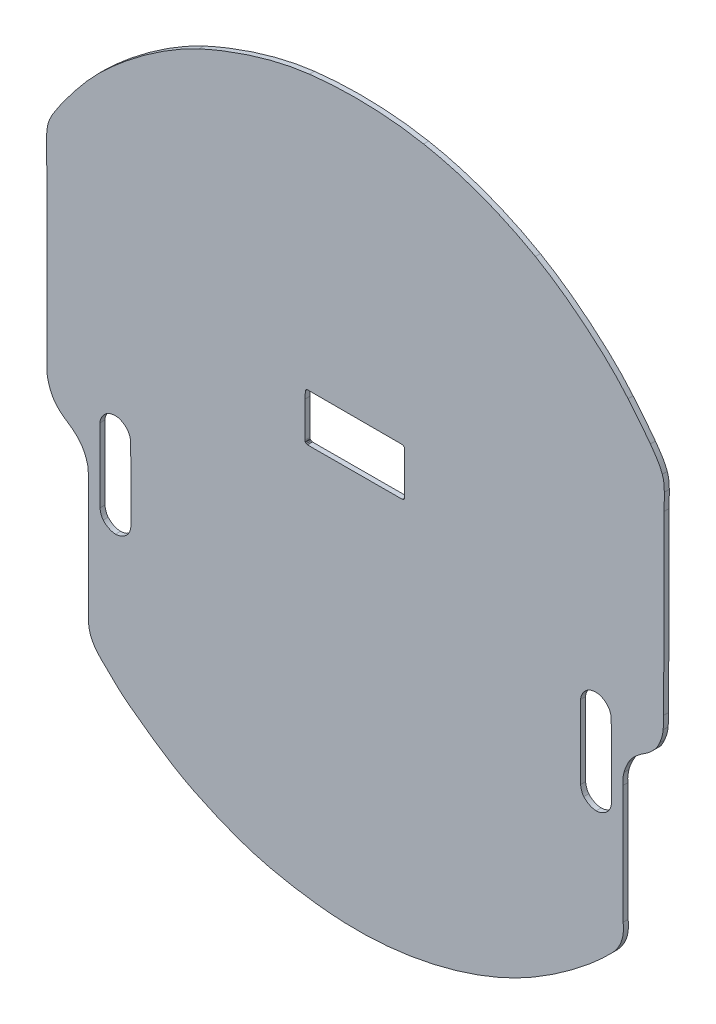
from build123d import *

# Parameters (mm, degrees)
BOSS_EXTRUDE1_DEPTH = 3.09


with BuildPart() as part:
    # Model → Boss-Extrude1 (new body)
    with BuildSketch(Plane.XY):
        with BuildLine():
            Line((32.991394077, 407.583971318), (33.227511856, 281.581752378))
            add(Edge.make_bspline(
                [(33.227511856, 281.581752378), (32.868682929, 277.527273844), (35.306656225, 271.332269837)],
                knots=[0, 0, 0, 1, 1, 1], degree=2))
            add(Edge.make_bspline(
                [(35.306656225, 271.332269837), (37.027868592, 266.958587981), (39.985006105, 263.165547305), (46.21976096, 259.169518249)],
                knots=[0, 0, 0, 0, 1, 1, 1, 1], degree=3))
            add(Edge.make_bspline(
                [(46.21976096, 259.169518249), (49.167061196, 257.280507614), (52.004779981, 254.877932524), (54.061744955, 252.177633115)],
                knots=[0, 0, 0, 0, 1, 1, 1, 1], degree=3))
            add(Edge.make_bspline(
                [(54.061744955, 252.177633115), (55.178759085, 250.71126606), (55.744043669, 249.636275438), (56.710796301, 247.517826276)],
                knots=[0, 0, 0, 0, 1, 1, 1, 1], degree=3))
            add(Edge.make_bspline(
                [(56.710796301, 247.517826276), (57.341702876, 246.135318374), (57.260729106, 246.533563849), (58.175067961, 243.47314552)],
                knots=[0, 0, 0, 0, 1, 1, 1, 1], degree=3))
            add(Edge.make_bspline(
                [(58.175067961, 243.47314552), (58.245897129, 243.236067231), (58.475340473, 242.643778545), (58.587518769, 241.756829152)],
                knots=[0, 0, 0, 0, 1, 1, 1, 1], degree=3))
            add(Edge.make_bspline(
                [(58.587518769, 241.756829152), (58.752115659, 240.455381726), (58.798989886, 238.577267145), (58.828773397, 236.730434162)],
                knots=[0, 0, 0, 0, 1, 1, 1, 1], degree=3))
            Line((58.828773397, 236.730434162), (58.884091825, 161.516615034))
            add(Edge.make_bspline(
                [(58.884091825, 161.516615034), (58.896182495, 157.557668689), (59.161050057, 156.032682116)],
                knots=[0, 0, 0, 1, 1, 1], degree=2))
            add(Edge.make_bspline(
                [(59.161050057, 156.032682116), (59.477358362, 154.211603705), (60.069141263, 152.083415532), (60.964587844, 150.242007936)],
                knots=[0, 0, 0, 0, 1, 1, 1, 1], degree=3))
            add(Edge.make_bspline(
                [(60.964587844, 150.242007936), (63.131630902, 145.785674549), (65.677762226, 143.362274605), (69.311519163, 139.967269864)],
                knots=[0, 0, 0, 0, 1, 1, 1, 1], degree=3))
            add(Edge.make_bspline(
                [(69.311519163, 139.967269864), (74.148765014, 135.447847746), (78.080395597, 130.972718907), (83.70611691, 126.812809249)],
                knots=[0, 0, 0, 0, 1, 1, 1, 1], degree=3))
            add(Edge.make_bspline(
                [(83.70611691, 126.812809249), (93.942545381, 119.243535855), (108.210085119, 108.349107593), (124.328928016, 100.399993517)],
                knots=[0, 0, 0, 0, 1, 1, 1, 1], degree=3))
            add(Edge.make_bspline(
                [(124.328928016, 100.399993517), (138.770611938, 93.277982427), (154.506893512, 86.784570087), (171.33433156, 82.818237836)],
                knots=[0, 0, 0, 0, 1, 1, 1, 1], degree=3))
            add(Edge.make_bspline(
                [(171.33433156, 82.818237836), (184.844846029, 79.63372877), (201.857266511, 77.04126754), (218.054038834, 76.369257504)],
                knots=[0, 0, 0, 0, 1, 1, 1, 1], degree=3))
            add(Edge.make_bspline(
                [(218.054038834, 76.369257504), (258.684244035, 74.68349055), (301.646652773, 86.336237446), (334.372498164, 105.351892157)],
                knots=[0, 0, 0, 0, 1, 1, 1, 1], degree=3))
            add(Edge.make_bspline(
                [(334.372498164, 105.351892157), (355.224876902, 117.468359601), (373.183510328, 132.155599732), (383.846199946, 143.221443829)],
                knots=[0, 0, 0, 0, 1, 1, 1, 1], degree=3))
            add(Edge.make_bspline(
                [(383.846199946, 143.221443829), (392.035384149, 151.720261902), (390.633271057, 163.015740579)],
                knots=[0, 0, 0, 1, 1, 1], degree=2))
            Line((390.633271057, 163.015740579), (390.420417461, 236.349293854))
            add(Edge.make_bspline(
                [(390.420417461, 236.349293854), (390.186475039, 239.783231997), (391.155554282, 243.852850362)],
                knots=[0, 0, 0, 1, 1, 1], degree=2))
            add(Edge.make_bspline(
                [(391.155554282, 243.852850362), (391.687736442, 246.087731231), (392.839269194, 248.39770913), (393.991837601, 250.708573357)],
                knots=[0, 0, 0, 0, 1, 1, 1, 1], degree=3))
            add(Edge.make_bspline(
                [(393.991837601, 250.708573357), (395.088090461, 252.906512653), (396.813530227, 254.747035366), (398.574818107, 256.364372018)],
                knots=[0, 0, 0, 0, 1, 1, 1, 1], degree=3))
            add(Edge.make_bspline(
                [(398.574818107, 256.364372018), (400.030433618, 257.70102208), (402.857001048, 259.710746735), (404.833912299, 260.932593236)],
                knots=[0, 0, 0, 0, 1, 1, 1, 1], degree=3))
            add(Edge.make_bspline(
                [(404.833912299, 260.932593236), (407.192691225, 262.390448652), (408.081143522, 263.52390802), (408.87013922, 264.331160148)],
                knots=[0, 0, 0, 0, 1, 1, 1, 1], degree=3))
            add(Edge.make_bspline(
                [(408.87013922, 264.331160148), (410.158942021, 265.649775362), (410.726456876, 266.118609155), (411.047880835, 266.596999876)],
                knots=[0, 0, 0, 0, 1, 1, 1, 1], degree=3))
            add(Edge.make_bspline(
                [(411.047880835, 266.596999876), (412.05971577, 268.102953037), (412.897811149, 269.937338892), (413.249312456, 270.696893086)],
                knots=[0, 0, 0, 0, 1, 1, 1, 1], degree=3))
            add(Edge.make_bspline(
                [(413.249312456, 270.696893086), (414.858185639, 274.173500215), (415.336561909, 277.272319668), (415.478311768, 278.845407358)],
                knots=[0, 0, 0, 0, 1, 1, 1, 1], degree=3))
            add(Edge.make_bspline(
                [(415.478311768, 278.845407358), (415.832443157, 282.775491684), (415.756214132, 286.74146266)],
                knots=[0, 0, 0, 1, 1, 1], degree=2))
            Line((415.756214132, 286.74146266), (416.09159294, 396.489105277))
            Line((416.09159294, 396.489105277), (416.181222859, 406.854590812))
            add(Edge.make_bspline(
                [(416.181222859, 406.854590812), (416.080306709, 410.49602123), (416.01712212, 412.667129836), (414.921452117, 415.855921215)],
                knots=[0, 0, 0, 0, 1, 1, 1, 1], degree=3))
            add(Edge.make_bspline(
                [(414.921452117, 415.855921215), (413.336437535, 420.468868278), (410.403236176, 424.408133806), (407.543421812, 428.481336019)],
                knots=[0, 0, 0, 0, 1, 1, 1, 1], degree=3))
            add(Edge.make_bspline(
                [(407.543421812, 428.481336019), (403.426707638, 434.344718478), (398.535559557, 439.898512347), (393.682393521, 445.861404392)],
                knots=[0, 0, 0, 0, 1, 1, 1, 1], degree=3))
            add(Edge.make_bspline(
                [(393.682393521, 445.861404392), (380.591531275, 461.945613059), (356.46965714, 481.848329881), (336.209359957, 493.504959279)],
                knots=[0, 0, 0, 0, 1, 1, 1, 1], degree=3))
            add(Edge.make_bspline(
                [(336.209359957, 493.504959279), (315.910748356, 505.183631269), (292.358142464, 514.508259444), (266.86314876, 519.300716829)],
                knots=[0, 0, 0, 0, 1, 1, 1, 1], degree=3))
            add(Edge.make_bspline(
                [(266.86314876, 519.300716829), (243.980491228, 523.602114783), (219.429229713, 524.135669788), (195.998821477, 521.39781223)],
                knots=[0, 0, 0, 0, 1, 1, 1, 1], degree=3))
            add(Edge.make_bspline(
                [(195.998821477, 521.39781223), (175.113388485, 518.957336984), (150.617830758, 511.425259019), (127.361051287, 500.649398803)],
                knots=[0, 0, 0, 0, 1, 1, 1, 1], degree=3))
            add(Edge.make_bspline(
                [(127.361051287, 500.649398803), (111.783138222, 493.431485578), (87.584755676, 478.347146418), (65.341463371, 456.497489719)],
                knots=[0, 0, 0, 0, 1, 1, 1, 1], degree=3))
            add(Edge.make_bspline(
                [(65.341463371, 456.497489719), (57.57302485, 448.866528378), (50.016919689, 439.332326984), (43.091021675, 429.854234006)],
                knots=[0, 0, 0, 0, 1, 1, 1, 1], degree=3))
            add(Edge.make_bspline(
                [(43.091021675, 429.854234006), (42.114711151, 428.51815235), (41.2599398, 427.115205917), (40.291560467, 425.760771491)],
                knots=[0, 0, 0, 0, 1, 1, 1, 1], degree=3))
            add(Edge.make_bspline(
                [(40.291560467, 425.760771491), (38.996935358, 423.950027472), (37.746280307, 422.061888714), (36.710367597, 420.220498941)],
                knots=[0, 0, 0, 0, 1, 1, 1, 1], degree=3))
            add(Edge.make_bspline(
                [(36.710367597, 420.220498941), (35.993248765, 418.945785865), (36.444080466, 419.903386197), (34.719209106, 416.277948219)],
                knots=[0, 0, 0, 0, 1, 1, 1, 1], degree=3))
            add(Edge.make_bspline(
                [(34.719209106, 416.277948219), (34.616058349, 416.061139866), (33.897155782, 414.156392092), (33.635892299, 412.896732141)],
                knots=[0, 0, 0, 0, 1, 1, 1, 1], degree=3))
            add(Edge.make_bspline(
                [(33.635892299, 412.896732141), (33.282668915, 411.193696242), (33.021643392, 409.935847483), (32.991394077, 407.583971318)],
                knots=[0, 0, 0, 0, 1, 1, 1, 1], degree=3))
        make_face()
        Polygon((193.427704374, 350.068263951), (193.356865572, 345.534802205), (193.333262272, 323.386944304), (193.380517042, 322.584152718), (193.545793129, 322.253586093), (193.994419607, 321.923019468), (194.419437968, 321.75772893), (194.773607893, 321.592452843), (253.412683013, 321.766279105), (253.83008088, 321.782994095), (254.364348801, 321.983347576), (254.698268058, 322.317266833), (254.982109783, 322.768070595), (255.048897488, 323.452600014), (255.132376098, 349.632012346), (254.965414061, 350.199671711), (254.581398004, 350.650461022), (254.080521527, 351.001076001), (253.429378735, 351.117950872), (252.360828442, 351.168047672), (195.485733905, 351.193096072), (194.943118123, 351.201525822), (194.56744511, 351.126390256), (194.308656602, 351.042902012), (194.008133606, 350.83420067), (193.724301515, 350.575412162), (193.498904451, 350.241497722), align=None, mode=Mode.SUBTRACT)
        with BuildLine():
            add(Edge.make_bspline(
                [(75.463247242, 277.627322934), (68.888523942, 277.734578256), (66.037548773, 271.651675473), (66.018536074, 269.03262922)],
                knots=[0, 0, 0, 0, 1, 1, 1, 1], degree=3))
            add(Edge.make_bspline(
                [(66.018536074, 269.03262922), (65.908043728, 253.81129458), (66.16159134, 238.588880932), (66.065742674, 223.367445135)],
                knots=[0, 0, 0, 0, 1, 1, 1, 1], degree=3))
            add(Edge.make_bspline(
                [(66.065742674, 223.367445135), (66.060154954, 222.478891681), (66.706620439, 219.301979024), (68.001906922, 217.842293148)],
                knots=[0, 0, 0, 0, 1, 1, 1, 1], degree=3))
            add(Edge.make_bspline(
                [(68.001906922, 217.842293148), (69.898976398, 215.704450744), (72.84137341, 214.099074703), (75.69934768, 214.064401937)],
                knots=[0, 0, 0, 0, 1, 1, 1, 1], degree=3))
            add(Edge.make_bspline(
                [(75.69934768, 214.064401937), (78.368524452, 214.032031697), (81.171859491, 215.446013877), (82.971774894, 217.417274787)],
                knots=[0, 0, 0, 0, 1, 1, 1, 1], degree=3))
            add(Edge.make_bspline(
                [(82.971774894, 217.417274787), (84.526105186, 219.119568868), (85.235504776, 221.62780967), (85.285731635, 223.934126649)],
                knots=[0, 0, 0, 0, 1, 1, 1, 1], degree=3))
            add(Edge.make_bspline(
                [(85.285731635, 223.934126649), (85.610657553, 238.853531729), (85.062145763, 267.248951924), (85.002390878, 268.702062595)],
                knots=[0, 0, 0, 0, 1, 1, 1, 1], degree=3))
            add(Edge.make_bspline(
                [(85.002390878, 268.702062595), (84.942635993, 270.155173266), (84.449510069, 271.7370857), (83.632908144, 272.999404635)],
                knots=[0, 0, 0, 0, 1, 1, 1, 1], degree=3))
            add(Edge.make_bspline(
                [(83.632908144, 272.999404635), (82.633871978, 274.543730018), (81.258974936, 275.82748942), (79.524455125, 276.68284411)],
                knots=[0, 0, 0, 0, 1, 1, 1, 1], degree=3))
            add(Edge.make_bspline(
                [(79.524455125, 276.68284411), (77.603690826, 277.630044539), (76.85292284, 277.604654132), (75.463247242, 277.627322934)],
                knots=[0, 0, 0, 0, 1, 1, 1, 1], degree=3))
        make_face(mode=Mode.SUBTRACT)
        with BuildLine():
            add(Edge.make_bspline(
                [(373.66196367, 278.099128816), (367.08724037, 278.206384138), (364.236265201, 272.123481355), (364.217252502, 269.504435102)],
                knots=[0, 0, 0, 0, 1, 1, 1, 1], degree=3))
            add(Edge.make_bspline(
                [(364.217252502, 269.504435102), (364.106760156, 254.283100462), (364.360307768, 239.060686814), (364.264459102, 223.839251017)],
                knots=[0, 0, 0, 0, 1, 1, 1, 1], degree=3))
            add(Edge.make_bspline(
                [(364.264459102, 223.839251017), (364.258871382, 222.950697563), (364.905336867, 219.773784906), (366.20062335, 218.314094213)],
                knots=[0, 0, 0, 0, 1, 1, 1, 1], degree=3))
            add(Edge.make_bspline(
                [(366.20062335, 218.314094213), (368.097692826, 216.176251809), (371.040089838, 214.570880585), (373.898064108, 214.536207819)],
                knots=[0, 0, 0, 0, 1, 1, 1, 1], degree=3))
            add(Edge.make_bspline(
                [(373.898064108, 214.536207819), (376.56724088, 214.503837579), (379.370575919, 215.917819759), (381.170491322, 217.889080669)],
                knots=[0, 0, 0, 0, 1, 1, 1, 1], degree=3))
            add(Edge.make_bspline(
                [(381.170491322, 217.889080669), (382.724821614, 219.59137475), (383.434221204, 222.099610735), (383.484448063, 224.405932531)],
                knots=[0, 0, 0, 0, 1, 1, 1, 1], degree=3))
            add(Edge.make_bspline(
                [(383.484448063, 224.405932531), (383.809373981, 239.325337611), (383.260862191, 267.720757806), (383.201107306, 269.173868477)],
                knots=[0, 0, 0, 0, 1, 1, 1, 1], degree=3))
            add(Edge.make_bspline(
                [(383.201107306, 269.173868477), (383.141352421, 270.626979148), (382.648226497, 272.208891582), (381.831624572, 273.471210517)],
                knots=[0, 0, 0, 0, 1, 1, 1, 1], degree=3))
            add(Edge.make_bspline(
                [(381.831624572, 273.471210517), (380.832588406, 275.0155359), (379.457691364, 276.299295302), (377.723171553, 277.154649992)],
                knots=[0, 0, 0, 0, 1, 1, 1, 1], degree=3))
            add(Edge.make_bspline(
                [(377.723171553, 277.154649992), (375.802407254, 278.101850421), (375.051639268, 278.076460014), (373.66196367, 278.099128816)],
                knots=[0, 0, 0, 0, 1, 1, 1, 1], degree=3))
        make_face(mode=Mode.SUBTRACT)
    extrude(amount=BOSS_EXTRUDE1_DEPTH)


solid = part.part
